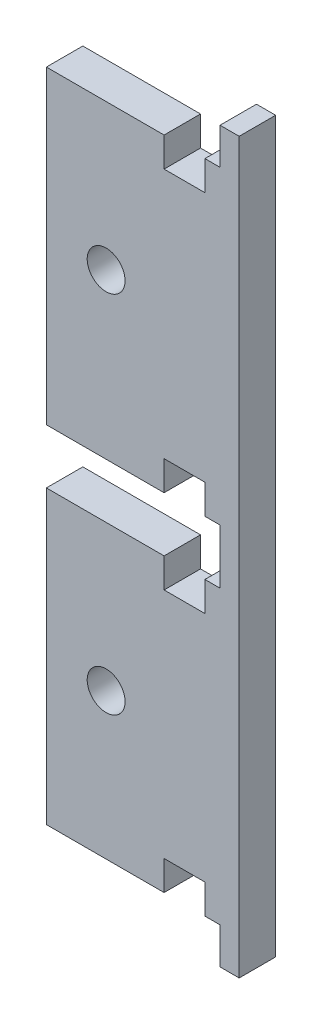
from build123d import *

# Parameters (mm, degrees)
SKETCH2_W               = 40.64
SKETCH2_H               = 127
BOSS_EXTRUDE1_DEPTH     = 6.35
M6_CLEARANCE_HOLE1_D    = 6.6
SKETCH5_W               = 7.0505
SKETCH5_H               = 127
CUT_EXTRUDE1_DEPTH      = 1
CUT_EXTRUDE1_DEPTH_BACK = 7.35
SKETCH6_W               = 27.8745
SKETCH6_H               = 3.175
CUT_EXTRUDE2_DEPTH      = 7.35
SKETCH7_W               = 6.35
SKETCH7_H               = 4.7625
CUT_EXTRUDE3_DEPTH      = 7.35


with BuildPart() as part:
    # Sketch2 → Boss-Extrude1 (new body)
    with BuildSketch(Plane.XY):
        with Locations((20.32, 63.5)):
            Rectangle(SKETCH2_W, SKETCH2_H)
    extrude(amount=BOSS_EXTRUDE1_DEPTH)

    # M6 Clearance Hole1 (through all)
    with Locations(Plane.XY.offset(6.35)):
        with Locations((17.4625, 31.75), (17.4625, 95.25)):
            Hole(M6_CLEARANCE_HOLE1_D / 2)

    # Sketch5 → Cut-Extrude1 (cut, two sides)
    with BuildSketch(Plane.XY.offset(6.35)) as cut_extrude1_sk:
        with Locations((3.52525, 63.5)):
            Rectangle(SKETCH5_W, SKETCH5_H)
    extrude(amount=CUT_EXTRUDE1_DEPTH, mode=Mode.SUBTRACT)
    extrude(cut_extrude1_sk.sketch, amount=-CUT_EXTRUDE1_DEPTH_BACK, mode=Mode.SUBTRACT)

    # Sketch6 → Cut-Extrude2 (cut, through all)
    with BuildSketch(Plane.XY.offset(6.35)):
        Polygon((7.0505, 123.825), (7.0505, 120.65), (37.30625, 120.65), (37.30625, 127), (34.925, 127), (34.925, 123.825), align=None)
        with Locations((20.98775, 125.4125)):
            Rectangle(SKETCH6_W, SKETCH6_H)
        Polygon((37.30625, 66.675), (7.0505, 66.675), (7.0505, 63.5), (34.925, 63.5), (34.925, 60.325), (7.0505, 60.325), (7.0505, 57.15), (37.30625, 57.15), align=None)
        with Locations((20.98775, 61.9125)):
            Rectangle(SKETCH6_W, SKETCH6_H)
        Polygon((37.30625, 0), (37.30625, 6.35), (7.0505, 6.35), (7.0505, 3.175), (34.925, 3.175), (34.925, 0), align=None)
        with Locations((20.98775, 1.5875)):
            Rectangle(SKETCH6_W, SKETCH6_H)
    extrude(amount=-CUT_EXTRUDE2_DEPTH, mode=Mode.SUBTRACT)

    # Sketch7 → Cut-Extrude3 (cut, through all)
    with BuildSketch(Plane.XY.offset(6.35)):
        with Locations((31.115, 8.73125)):
            Rectangle(SKETCH7_W, SKETCH7_H)
        Polygon((27.94, 11.1125), (34.29, 11.1125), (34.29, 6.35), (34.671, 6.35), (34.671, 11.4935), (27.559, 11.4935), (27.559, 6.35), (27.94, 6.35), align=None)
        Polygon((34.671, 6.35), (34.29, 6.35), (27.94, 6.35), (27.559, 6.35), (27.559, 5.969), (34.671, 5.969), align=None)
        with Locations((31.115, 54.76875)):
            Rectangle(SKETCH7_W, SKETCH7_H)
        Polygon((34.671, 57.15), (34.29, 57.15), (34.29, 52.3875), (27.94, 52.3875), (27.94, 57.15), (27.559, 57.15), (27.559, 52.0065), (34.671, 52.0065), align=None)
        Polygon((27.94, 57.15), (34.29, 57.15), (34.671, 57.15), (34.671, 57.531), (27.559, 57.531), (27.559, 57.15), align=None)
        Polygon((34.671, 66.675), (34.29, 66.675), (27.94, 66.675), (27.559, 66.675), (27.559, 66.294), (34.671, 66.294), align=None)
        with Locations((31.115, 69.05625)):
            Rectangle(SKETCH7_W, SKETCH7_H)
        Polygon((27.94, 71.4375), (34.29, 71.4375), (34.29, 66.675), (34.671, 66.675), (34.671, 71.8185), (27.559, 71.8185), (27.559, 66.675), (27.94, 66.675), align=None)
        with Locations((31.115, 118.26875)):
            Rectangle(SKETCH7_W, SKETCH7_H)
        Polygon((27.559, 115.5065), (34.671, 115.5065), (34.671, 120.65), (34.29, 120.65), (34.29, 115.8875), (27.94, 115.8875), (27.94, 120.65), (27.559, 120.65), align=None)
        Polygon((34.29, 120.65), (34.671, 120.65), (34.671, 121.031), (27.559, 121.031), (27.559, 120.65), (27.94, 120.65), align=None)
    extrude(amount=-CUT_EXTRUDE3_DEPTH, mode=Mode.SUBTRACT)


solid = part.part
